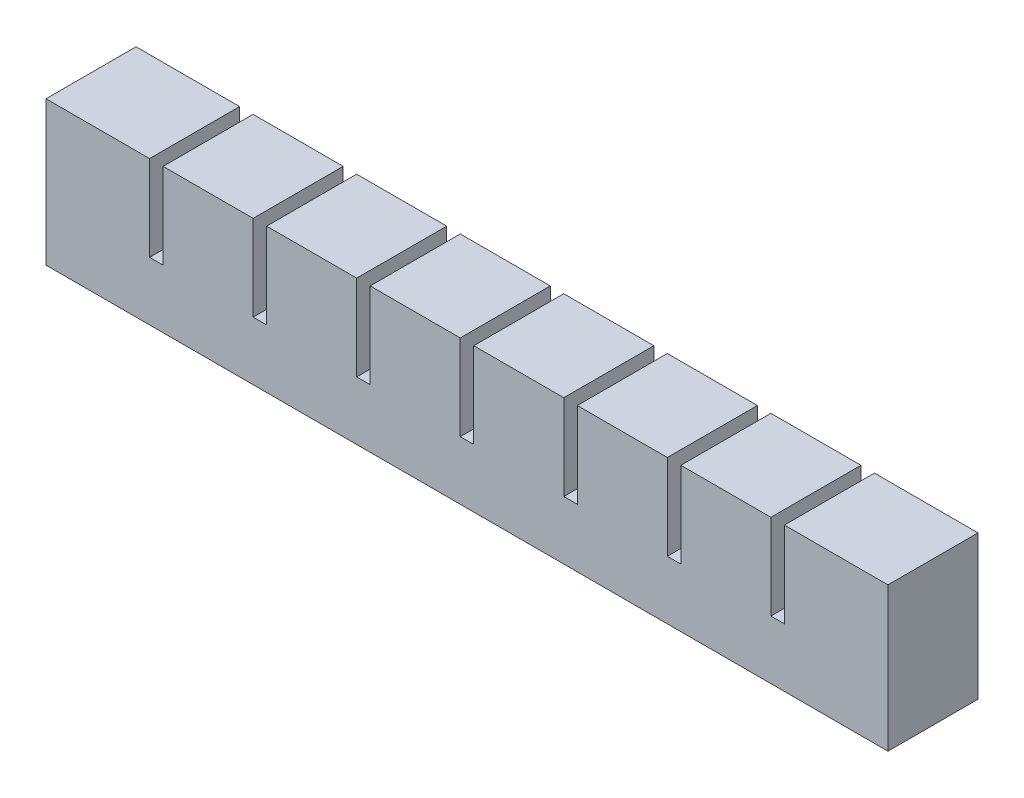
from build123d import *

# Parameters (mm, degrees)
SKETCH1_W           = 20
SKETCH1_H           = 25
BOSS_EXTRUDE1_DEPTH = 20
SKETCH2_W           = 8
SKETCH2_H           = 8
CUT_EXTRUDE1_DEPTH  = 20
SKETCH3_W           = 20
SKETCH3_H           = 6
BOSS_EXTRUDE2_DEPTH = 3
LPATTERN1_COUNT     = 8
LPATTERN1_PITCH     = 23
SKETCH4_W           = 20
SKETCH4_H           = 19
BOSS_EXTRUDE3_DEPTH = 3
SKETCH5_W           = 20
SKETCH5_H           = 25
BOSS_EXTRUDE4_DEPTH = 3
SKETCH6_W           = 153
SKETCH6_H           = 2
CUT_EXTRUDE2_DEPTH  = 2
SKETCH7_W           = 187
SKETCH7_H           = 20
BOSS_EXTRUDE5_DEPTH = 7


with BuildPart() as part:
    # Sketch1 → Boss-Extrude1 (new body)
    with BuildSketch(Plane.XY):
        with Locations((10, 12.5)):
            Rectangle(SKETCH1_W, SKETCH1_H)
    extrude(amount=BOSS_EXTRUDE1_DEPTH)

    # Sketch2 → Cut-Extrude1 (cut)
    with BuildSketch(Plane.XZ):
        with Locations((10, 10)):
            Rectangle(SKETCH2_W, SKETCH2_H)
    extrude(amount=-CUT_EXTRUDE1_DEPTH, mode=Mode.SUBTRACT)

    # Sketch3 → Boss-Extrude2 (add)
    with BuildSketch(Plane(origin=(20, 0, 0), x_dir=(0, 0, -1), z_dir=(1, 0, 0))):
        with Locations((-10, 3)):
            Rectangle(SKETCH3_W, SKETCH3_H)
    extrude(amount=BOSS_EXTRUDE2_DEPTH)


with BuildPart() as lpattern1_1:
    # LPattern1: pattern copy
    add(part.part.moved(Location(Vector(1, 0, 0) * (1 * LPATTERN1_PITCH))))


with BuildPart() as lpattern1_2:
    # LPattern1: pattern copy
    add(part.part.moved(Location(Vector(1, 0, 0) * (2 * LPATTERN1_PITCH))))


with BuildPart() as lpattern1_3:
    # LPattern1: pattern copy
    add(part.part.moved(Location(Vector(1, 0, 0) * (3 * LPATTERN1_PITCH))))


with BuildPart() as lpattern1_4:
    # LPattern1: pattern copy
    add(part.part.moved(Location(Vector(1, 0, 0) * (4 * LPATTERN1_PITCH))))


with BuildPart() as lpattern1_5:
    # LPattern1: pattern copy
    add(part.part.moved(Location(Vector(1, 0, 0) * (5 * LPATTERN1_PITCH))))


with BuildPart() as lpattern1_6:
    # LPattern1: pattern copy
    add(part.part.moved(Location(Vector(1, 0, 0) * (6 * LPATTERN1_PITCH))))


with BuildPart() as lpattern1_7:
    # LPattern1: pattern copy
    add(part.part.moved(Location(Vector(1, 0, 0) * (7 * LPATTERN1_PITCH))))


with BuildPart() as lpattern1_1_1:
    add(lpattern1_1.part)

    # Combine1: union LPattern1_2, LPattern1_3, part, LPattern1_4, LPattern1_5, LPattern1_6, LPattern1_7
    add(lpattern1_2.part)
    add(lpattern1_3.part)
    add(part.part)
    add(lpattern1_4.part)
    add(lpattern1_5.part)
    add(lpattern1_6.part)
    add(lpattern1_7.part)

    # Sketch4 → Boss-Extrude3 (add)
    with BuildSketch(Plane(origin=(181, 0, 0), x_dir=(0, 0, -1), z_dir=(1, 0, 0))):
        with Locations((-10, 15.5)):
            Rectangle(SKETCH4_W, SKETCH4_H)
    extrude(amount=BOSS_EXTRUDE3_DEPTH)

    # Sketch5 → Boss-Extrude4 (add)
    with BuildSketch(Plane.ZY):
        with Locations((10, 12.5)):
            Rectangle(SKETCH5_W, SKETCH5_H)
    extrude(amount=BOSS_EXTRUDE4_DEPTH)

    # Sketch6 → Cut-Extrude2 (cut)
    with BuildSketch(Plane.XZ):
        with Locations((90.5, 10)):
            Rectangle(SKETCH6_W, SKETCH6_H)
    extrude(amount=-CUT_EXTRUDE2_DEPTH, mode=Mode.SUBTRACT)

    # Sketch7 → Boss-Extrude5 (add)
    with BuildSketch(Plane.XZ):
        with Locations((90.5, 10)):
            Rectangle(SKETCH7_W, SKETCH7_H)
    extrude(amount=BOSS_EXTRUDE5_DEPTH)


solid = lpattern1_1_1.part
